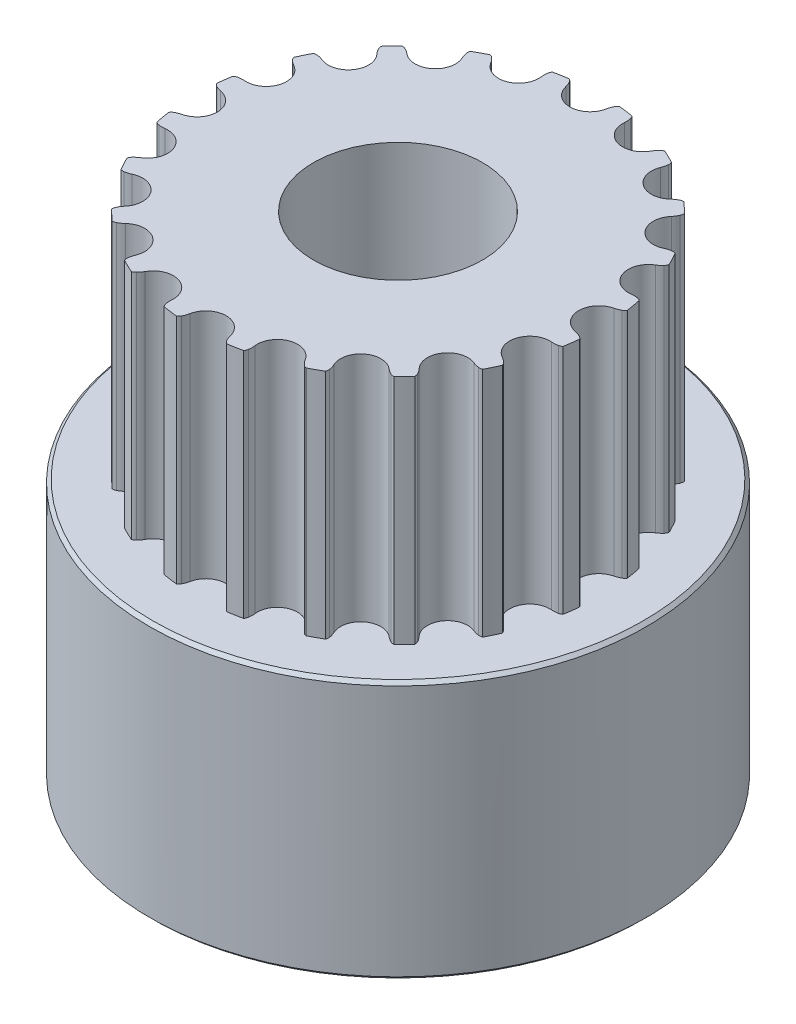
from build123d import *

# Parameters (mm, degrees)
P_IDAT_START            = 7.8
SKICA1_R                = 2.5
P_IDAT_VYSUNUT_M1_DEPTH = 7
SKICA2_R                = 3.5
SKICA2_R_2              = 2.5
P_IDAT_VYSUNUT_M2_DEPTH = 7.8
SKICA6_R                = 7.5
SKICA6_R_2              = 3.5
P_IDAT_VYSUNUT_M5_DEPTH = 7.8
ZKOSEN_3_SIZE           = 0.1
SKETCH19_R              = 1.5
CUT_EXTRUDE6_DEPTH      = 8
SKETCH20_R              = 1.5
CUT_EXTRUDE7_DEPTH      = 8
SKETCH21_R              = 2.55
CUT_EXTRUDE8_DEPTH      = 30


with BuildPart() as part:
    # Skica1 → Přidat vysunutím1 (new body)
    with BuildSketch(Plane(origin=(0, 0, 0), x_dir=(1, 0, 0), z_dir=(0, 1, 0)).offset(P_IDAT_START)):
        with BuildLine():
            ThreePointArc((-5.730143195, 1.098270155), (-5.09645097, 1.530497044), (-5.387174672, 2.240331989))
            ThreePointArc((-5.387174672, 2.240331989), (-5.468060657, 2.292707421), (-5.540463547, 2.356296335))
            ThreePointArc((-5.540463547, 2.356296335), (-5.573874331, 2.399596558), (-5.596043873, 2.44959357))
            ThreePointArc((-5.596043873, 2.44959357), (-5.50369925, 2.650567912), (-5.404139771, 2.848067596))
            ThreePointArc((-5.404139771, 2.848067596), (-5.351227535, 2.86190541), (-5.296542742, 2.862779021))
            ThreePointArc((-5.296542742, 2.862779021), (-5.201685094, 2.845815675), (-5.110305882, 2.815228615))
            ThreePointArc((-5.110305882, 2.815228615), (-4.374063308, 3.030479148), (-4.431206919, 3.795410862))
            ThreePointArc((-4.431206919, 3.795410862), (-4.491949163, 3.870218002), (-4.541158349, 3.953068377))
            ThreePointArc((-4.541158349, 3.953068377), (-4.559553388, 4.004573836), (-4.565187949, 4.058974585))
            ThreePointArc((-4.565187949, 4.058974585), (-4.415258506, 4.221576484), (-4.259541056, 4.378644275))
            ThreePointArc((-4.259541056, 4.378644275), (-4.204942409, 4.375454038), (-4.15266412, 4.359386362))
            ThreePointArc((-4.15266412, 4.359386362), (-4.067691098, 4.313940635), (-3.990236225, 4.256612884))
            ThreePointArc((-3.990236225, 4.256612884), (-3.223511854, 4.233816838), (-3.041481758, 4.978968476))
            ThreePointArc((-3.041481758, 4.978968476), (-3.076134388, 5.06888468), (-3.097332931, 5.162886543))
            ThreePointArc((-3.097332931, 5.162886543), (-3.09891159, 5.217555525), (-3.08745962, 5.271034888))
            ThreePointArc((-3.08745962, 5.271034888), (-2.894621497, 5.379347737), (-2.697988784, 5.480608745))
            ThreePointArc((-2.697988784, 5.480608745), (-2.647048223, 5.460702739), (-2.6022938, 5.429266591))
            ThreePointArc((-2.6022938, 5.429266591), (-2.535523156, 5.359787029), (-2.479574443, 5.281330225))
            ThreePointArc((-2.479574443, 5.281330225), (-1.7574206, 5.022719037), (-1.354035171, 5.675149965))
            ThreePointArc((-1.354035171, 5.675149965), (-1.359206146, 5.771373608), (-1.350318985, 5.867325402))
            ThreePointArc((-1.350318985, 5.867325402), (-1.334926735, 5.919806527), (-1.307509232, 5.967129569))
            ThreePointArc((-1.307509232, 5.967129569), (-1.090638767, 6.010550954), (-0.872338572, 6.046093045))
            ThreePointArc((-0.872338572, 6.046093045), (-0.830042514, 6.01141981), (-0.797192832, 5.967692379))
            ThreePointArc((-0.797192832, 5.967692379), (-0.755160541, 5.880980125), (-0.726194639, 5.789074167))
            ThreePointArc((-0.726194639, 5.789074167), (-0.119300773, 5.319962501), (0.465953812, 5.815808234))
            ThreePointArc((0.465953812, 5.815808234), (0.490770664, 5.908920276), (0.528873591, 5.997429571))
            ThreePointArc((0.528873591, 5.997429571), (0.55973005, 6.04258562), (0.600429269, 6.079120034))
            ThreePointArc((0.600429269, 6.079120034), (0.820103284, 6.053399565), (1.038702217, 6.019743632))
            ThreePointArc((1.038702217, 6.019743632), (1.06821354, 5.973697225), (1.085942924, 5.921958857))
            ThreePointArc((1.085942924, 5.921958857), (1.099122448, 5.826501911), (1.098270155, 5.730143195))
            ThreePointArc((1.098270155, 5.730143195), (1.530497044, 5.09645097), (2.240331989, 5.387174672))
            ThreePointArc((2.240331989, 5.387174672), (2.292707421, 5.468060657), (2.356296335, 5.540463547))
            ThreePointArc((2.356296335, 5.540463547), (2.399596558, 5.573874331), (2.44959357, 5.596043873))
            ThreePointArc((2.44959357, 5.596043873), (2.650567912, 5.50369925), (2.848067596, 5.404139771))
            ThreePointArc((2.848067596, 5.404139771), (2.86190541, 5.351227535), (2.862779021, 5.296542742))
            ThreePointArc((2.862779021, 5.296542742), (2.845815675, 5.201685094), (2.815228615, 5.110305882))
            ThreePointArc((2.815228615, 5.110305882), (3.030479148, 4.374063308), (3.795410862, 4.431206919))
            ThreePointArc((3.795410862, 4.431206919), (3.870218002, 4.491949163), (3.953068377, 4.541158349))
            ThreePointArc((3.953068377, 4.541158349), (4.004573836, 4.559553388), (4.058974585, 4.565187949))
            ThreePointArc((4.058974585, 4.565187949), (4.221576484, 4.415258506), (4.378644275, 4.259541056))
            ThreePointArc((4.378644275, 4.259541056), (4.375454038, 4.204942409), (4.359386362, 4.15266412))
            ThreePointArc((4.359386362, 4.15266412), (4.313940635, 4.067691098), (4.256612884, 3.990236225))
            ThreePointArc((4.256612884, 3.990236225), (4.233816838, 3.223511854), (4.978968476, 3.041481758))
            ThreePointArc((4.978968476, 3.041481758), (5.06888468, 3.076134388), (5.162886543, 3.097332931))
            ThreePointArc((5.162886543, 3.097332931), (5.217555525, 3.09891159), (5.271034888, 3.08745962))
            ThreePointArc((5.271034888, 3.08745962), (5.379347737, 2.894621497), (5.480608745, 2.697988784))
            ThreePointArc((5.480608745, 2.697988784), (5.460702739, 2.647048223), (5.429266591, 2.6022938))
            ThreePointArc((5.429266591, 2.6022938), (5.359787029, 2.535523156), (5.281330225, 2.479574443))
            ThreePointArc((5.281330225, 2.479574443), (5.022719037, 1.7574206), (5.675149965, 1.354035171))
            ThreePointArc((5.675149965, 1.354035171), (5.771373608, 1.359206146), (5.867325402, 1.350318985))
            ThreePointArc((5.867325402, 1.350318985), (5.919806527, 1.334926735), (5.967129569, 1.307509232))
            ThreePointArc((5.967129569, 1.307509232), (6.010550954, 1.090638767), (6.046093045, 0.872338572))
            ThreePointArc((6.046093045, 0.872338572), (6.01141981, 0.830042514), (5.967692379, 0.797192832))
            ThreePointArc((5.967692379, 0.797192832), (5.880980125, 0.755160541), (5.789074167, 0.726194639))
            ThreePointArc((5.789074167, 0.726194639), (5.319962501, 0.119300773), (5.815808234, -0.465953812))
            ThreePointArc((5.815808234, -0.465953812), (5.908920276, -0.490770664), (5.997429571, -0.528873591))
            ThreePointArc((5.997429571, -0.528873591), (6.04258562, -0.55973005), (6.079120034, -0.600429269))
            ThreePointArc((6.079120034, -0.600429269), (6.053399565, -0.820103284), (6.019743632, -1.038702217))
            ThreePointArc((6.019743632, -1.038702217), (5.973697225, -1.06821354), (5.921958857, -1.085942924))
            ThreePointArc((5.921958857, -1.085942924), (5.826501911, -1.099122448), (5.730143195, -1.098270155))
            ThreePointArc((5.730143195, -1.098270155), (5.09645097, -1.530497044), (5.387174672, -2.240331989))
            ThreePointArc((5.387174672, -2.240331989), (5.468060657, -2.292707421), (5.540463547, -2.356296335))
            ThreePointArc((5.540463547, -2.356296335), (5.573874331, -2.399596558), (5.596043873, -2.44959357))
            ThreePointArc((5.596043873, -2.44959357), (5.50369925, -2.650567911), (5.404139771, -2.848067596))
            ThreePointArc((5.404139771, -2.848067596), (5.351227535, -2.86190541), (5.296542742, -2.862779021))
            ThreePointArc((5.296542742, -2.862779021), (5.201685094, -2.845815675), (5.110305882, -2.815228615))
            ThreePointArc((5.110305882, -2.815228615), (4.374063308, -3.030479148), (4.431206919, -3.795410862))
            ThreePointArc((4.431206919, -3.795410862), (4.491949163, -3.870218002), (4.541158349, -3.953068377))
            ThreePointArc((4.541158349, -3.953068377), (4.559553388, -4.004573836), (4.565187949, -4.058974585))
            ThreePointArc((4.565187949, -4.058974585), (4.415258506, -4.221576484), (4.259541056, -4.378644275))
            ThreePointArc((4.259541056, -4.378644275), (4.204942409, -4.375454038), (4.15266412, -4.359386362))
            ThreePointArc((4.15266412, -4.359386362), (4.067691098, -4.313940635), (3.990236225, -4.256612884))
            ThreePointArc((3.990236225, -4.256612884), (3.223511854, -4.233816838), (3.041481758, -4.978968476))
            ThreePointArc((3.041481758, -4.978968476), (3.076134388, -5.06888468), (3.097332931, -5.162886543))
            ThreePointArc((3.097332931, -5.162886543), (3.09891159, -5.217555525), (3.08745962, -5.271034888))
            ThreePointArc((3.08745962, -5.271034888), (2.894621497, -5.379347737), (2.697988784, -5.480608745))
            ThreePointArc((2.697988784, -5.480608745), (2.647048223, -5.460702739), (2.6022938, -5.429266591))
            ThreePointArc((2.6022938, -5.429266591), (2.535523156, -5.359787029), (2.479574443, -5.281330225))
            ThreePointArc((2.479574443, -5.281330225), (1.7574206, -5.022719037), (1.354035171, -5.675149965))
            ThreePointArc((1.354035171, -5.675149965), (1.359206146, -5.771373608), (1.350318985, -5.867325402))
            ThreePointArc((1.350318985, -5.867325402), (1.334926735, -5.919806527), (1.307509232, -5.967129569))
            ThreePointArc((1.307509232, -5.967129569), (1.090638767, -6.010550954), (0.872338572, -6.046093045))
            ThreePointArc((0.872338572, -6.046093045), (0.830042514, -6.01141981), (0.797192832, -5.967692379))
            ThreePointArc((0.797192832, -5.967692379), (0.755160541, -5.880980125), (0.726194639, -5.789074167))
            ThreePointArc((0.726194639, -5.789074167), (0.119300773, -5.319962501), (-0.465953812, -5.815808234))
            ThreePointArc((-0.465953812, -5.815808234), (-0.490770664, -5.908920276), (-0.528873591, -5.997429571))
            ThreePointArc((-0.528873591, -5.997429571), (-0.55973005, -6.04258562), (-0.600429269, -6.079120034))
            ThreePointArc((-0.600429269, -6.079120034), (-0.820103284, -6.053399565), (-1.038702217, -6.019743632))
            ThreePointArc((-1.038702217, -6.019743632), (-1.06821354, -5.973697225), (-1.085942924, -5.921958857))
            ThreePointArc((-1.085942924, -5.921958857), (-1.099122448, -5.826501911), (-1.098270155, -5.730143195))
            ThreePointArc((-1.098270155, -5.730143195), (-1.530497044, -5.09645097), (-2.240331989, -5.387174672))
            ThreePointArc((-2.240331989, -5.387174672), (-2.292707421, -5.468060657), (-2.356296335, -5.540463547))
            ThreePointArc((-2.356296335, -5.540463547), (-2.399596558, -5.573874331), (-2.44959357, -5.596043873))
            ThreePointArc((-2.44959357, -5.596043873), (-2.650567912, -5.50369925), (-2.848067596, -5.404139771))
            ThreePointArc((-2.848067596, -5.404139771), (-2.86190541, -5.351227535), (-2.862779021, -5.296542742))
            ThreePointArc((-2.862779021, -5.296542742), (-2.845815675, -5.201685094), (-2.815228615, -5.110305882))
            ThreePointArc((-2.815228615, -5.110305882), (-3.030479148, -4.374063308), (-3.795410862, -4.431206919))
            ThreePointArc((-3.795410862, -4.431206919), (-3.870218002, -4.491949163), (-3.953068377, -4.541158349))
            ThreePointArc((-3.953068377, -4.541158349), (-4.004573836, -4.559553388), (-4.058974585, -4.565187949))
            ThreePointArc((-4.058974585, -4.565187949), (-4.221576484, -4.415258506), (-4.378644275, -4.259541056))
            ThreePointArc((-4.378644275, -4.259541056), (-4.375454038, -4.204942409), (-4.359386362, -4.15266412))
            ThreePointArc((-4.359386362, -4.15266412), (-4.313940635, -4.067691098), (-4.256612884, -3.990236225))
            ThreePointArc((-4.256612884, -3.990236225), (-4.233816838, -3.223511854), (-4.978968476, -3.041481758))
            ThreePointArc((-4.978968476, -3.041481758), (-5.06888468, -3.076134388), (-5.162886543, -3.097332931))
            ThreePointArc((-5.162886543, -3.097332931), (-5.217555525, -3.09891159), (-5.271034888, -3.08745962))
            ThreePointArc((-5.271034888, -3.08745962), (-5.379347737, -2.894621497), (-5.480608745, -2.697988784))
            ThreePointArc((-5.480608745, -2.697988784), (-5.460702739, -2.647048223), (-5.429266591, -2.6022938))
            ThreePointArc((-5.429266591, -2.6022938), (-5.359787029, -2.535523156), (-5.281330225, -2.479574443))
            ThreePointArc((-5.281330225, -2.479574443), (-5.022719037, -1.7574206), (-5.675149965, -1.354035171))
            ThreePointArc((-5.675149965, -1.354035171), (-5.771373608, -1.359206146), (-5.867325402, -1.350318985))
            ThreePointArc((-5.867325402, -1.350318985), (-5.919806527, -1.334926735), (-5.967129569, -1.307509232))
            ThreePointArc((-5.967129569, -1.307509232), (-6.010550954, -1.090638767), (-6.046093045, -0.872338572))
            ThreePointArc((-6.046093045, -0.872338572), (-6.01141981, -0.830042514), (-5.967692379, -0.797192832))
            ThreePointArc((-5.967692379, -0.797192832), (-5.880980125, -0.755160541), (-5.789074167, -0.726194639))
            ThreePointArc((-5.789074167, -0.726194639), (-5.319962501, -0.119300773), (-5.815808234, 0.465953812))
            ThreePointArc((-5.815808234, 0.465953812), (-5.908920276, 0.490770664), (-5.997429571, 0.528873591))
            ThreePointArc((-5.997429571, 0.528873591), (-6.04258562, 0.55973005), (-6.079120034, 0.600429269))
            ThreePointArc((-6.079120034, 0.600429269), (-6.053399565, 0.820103284), (-6.019743632, 1.038702217))
            ThreePointArc((-6.019743632, 1.038702217), (-5.973697225, 1.06821354), (-5.921958857, 1.085942924))
            ThreePointArc((-5.921958857, 1.085942924), (-5.826501911, 1.099122448), (-5.730143195, 1.098270155))
        make_face()
        Circle(SKICA1_R, mode=Mode.SUBTRACT)
    extrude(amount=P_IDAT_VYSUNUT_M1_DEPTH)

    # Skica2 → Přidat vysunutím2 (add)
    with BuildSketch(Plane.XZ.offset(-7.8)):
        Circle(SKICA2_R)
        Circle(SKICA2_R_2, mode=Mode.SUBTRACT)
    extrude(amount=P_IDAT_VYSUNUT_M2_DEPTH)


with BuildPart() as body_2:
    # Skica6 → Přidat vysunutím5 (new body)
    with BuildSketch(Plane.XZ):
        Circle(SKICA6_R)
        Circle(SKICA6_R_2, mode=Mode.SUBTRACT)
    extrude(amount=-P_IDAT_VYSUNUT_M5_DEPTH)

    # Zkosení3
    zkosen_3_edges = [body_2.edges().sort_by_distance(p)[0] for p in [
        (-7.5, 0, 0),
        (-7.5, 7.8, 0),
    ]]
    chamfer(zkosen_3_edges, length=ZKOSEN_3_SIZE)


with BuildPart() as cut_extrude6_tool:
    # Sketch19 → Cut-Extrude6 (new body)
    with BuildSketch(Plane(origin=(0, 0, -7.5), x_dir=(-1, 0, 0), z_dir=(0, 0, -1))):
        with Locations((0, 3.9)):
            Circle(SKETCH19_R)
    extrude(amount=-CUT_EXTRUDE6_DEPTH)


with BuildPart() as part_1:
    add(part.part)

    # Cut-Extrude6: cut by cut_extrude6_tool
    add(cut_extrude6_tool.part, mode=Mode.SUBTRACT)


with BuildPart() as body_2_1:
    add(body_2.part)

    # Cut-Extrude6: cut by cut_extrude6_tool
    add(cut_extrude6_tool.part, mode=Mode.SUBTRACT)


with BuildPart() as cut_extrude7_tool:
    # Sketch20 → Cut-Extrude7 (new body)
    with BuildSketch(Plane.ZY.offset(7.5)):
        with Locations((0, 3.9)):
            Circle(SKETCH20_R)
    extrude(amount=-CUT_EXTRUDE7_DEPTH)


with BuildPart() as part_2:
    add(part_1.part)

    # Cut-Extrude7: cut by cut_extrude7_tool
    add(cut_extrude7_tool.part, mode=Mode.SUBTRACT)

    # Sketch21 → Cut-Extrude8 (cut)
    with BuildSketch(Plane(origin=(0, 16, 0), x_dir=(1, 0, 0), z_dir=(0, 1, 0))):
        Circle(SKETCH21_R)
    extrude(amount=-CUT_EXTRUDE8_DEPTH, mode=Mode.SUBTRACT)


with BuildPart() as body_2_2:
    add(body_2_1.part)

    # Cut-Extrude7: cut by cut_extrude7_tool
    add(cut_extrude7_tool.part, mode=Mode.SUBTRACT)


solid = Compound([part_2.part, body_2_2.part])
